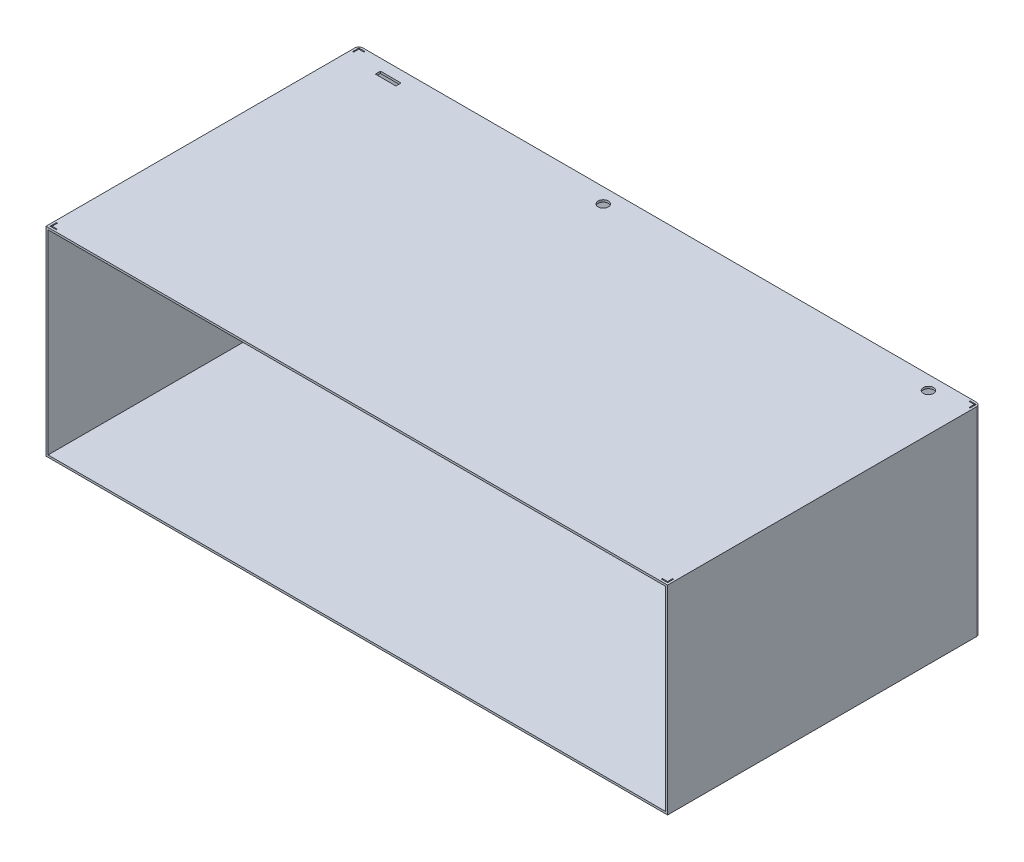
from build123d import *

# Parameters (mm, degrees)
SKETCH1_W            = 1208
SKETCH1_H            = 387
BOSS_EXTRUDE1_DEPTH  = 608
SKETCH2_W            = 1200
SKETCH2_H            = 379
CUT_EXTRUDE1_DEPTH   = 604
FILLET1_R            = 8
CUT_EXTRUDE2_DEPTH   = 2
MIRROR2_COPY_1_DEPTH = 2
SKETCH5_R            = 10
SKETCH5_W            = 40
SKETCH5_H            = 10
CUT_EXTRUDE4_DEPTH   = 4


with BuildPart() as part:
    # Sketch1 → Boss-Extrude1 (new body)
    with BuildSketch(Plane.XY):
        Rectangle(SKETCH1_W, SKETCH1_H)
    extrude(amount=BOSS_EXTRUDE1_DEPTH)

    # Sketch2 → Cut-Extrude1 (cut)
    with BuildSketch(Plane.XY.offset(608)):
        Rectangle(SKETCH2_W, SKETCH2_H)
    extrude(amount=-CUT_EXTRUDE1_DEPTH, mode=Mode.SUBTRACT)

    # Fillet1
    fillet1_edges = [part.edges().sort_by_distance(p)[0] for p in [
        (-604, 0, 0),
        (604, 0, 0),
    ]]
    fillet(fillet1_edges, radius=FILLET1_R)

    # Sketch4 → Cut-Extrude2 (cut)
    with BuildSketch(Plane(origin=(0, 193.5, 0), x_dir=(1, 0, 0), z_dir=(0, 1, 0))):
        Polygon((-600, -604), (-588, -604), (-588, -602), (-598, -602), (-598, -592), (-600, -592), align=None)
    cut_extrude2 = extrude(amount=-CUT_EXTRUDE2_DEPTH, mode=Mode.SUBTRACT)

    # Mirror1: Cut-Extrude2 across plane
    add(cut_extrude2.mirror(Plane(origin=(0, 0, 0), x_dir=(0, 0, 1), z_dir=(1, 0, 0))), mode=Mode.SUBTRACT)

    # Mirror2: Cut-Extrude2 across plane
    add(cut_extrude2.mirror(Plane.XY.offset(304)), mode=Mode.SUBTRACT)

    # Mirror2 copy 1 sketch → Mirror2 copy 1 (cut)
    with BuildSketch(Plane(origin=(0, 193.5, 608), x_dir=(-1, 0, 0), z_dir=(0, 1, 0))):
        Polygon((-600, -604), (-588, -604), (-588, -602), (-598, -602), (-598, -592), (-600, -592), align=None)
    extrude(amount=-MIRROR2_COPY_1_DEPTH, mode=Mode.SUBTRACT)

    # Sketch5 → Cut-Extrude4 (cut)
    with BuildSketch(Plane(origin=(0, 193.5, 0), x_dir=(1, 0, 0), z_dir=(0, 1, 0))):
        with Locations((-100, -29)):
            Circle(SKETCH5_R)
        with Locations((530, -27)):
            Circle(SKETCH5_R)
        with Locations((-520, -27)):
            Rectangle(SKETCH5_W, SKETCH5_H)
    extrude(amount=-CUT_EXTRUDE4_DEPTH, mode=Mode.SUBTRACT)


solid = part.part
